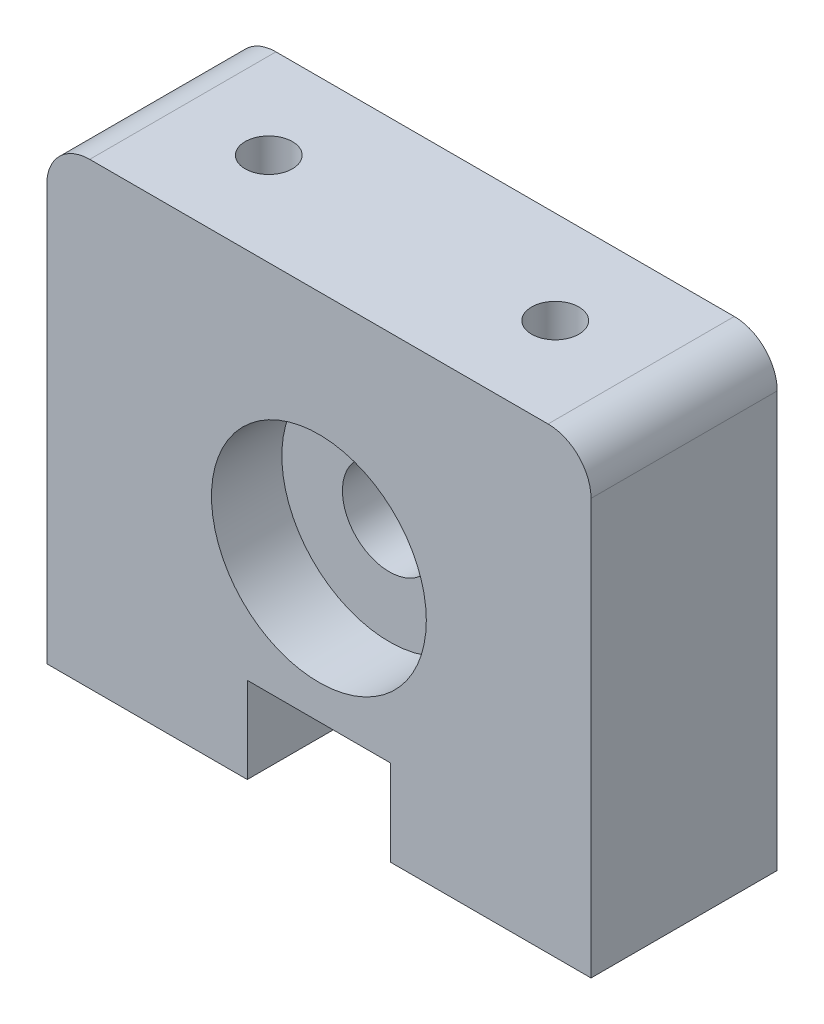
from build123d import *

# Parameters (mm, degrees)
SKETCH1_R                 = 7.5
BOSS_EXTRUDE1_DEPTH       = 13
SKETCH3_R                 = 8.7376
SKETCH3_R_2               = 3.27025
BOSS_EXTRUDE2_DEPTH       = 1.5875
BOSS_EXTRUDE2_DEPTH_BACK  = 1.5875
M4X0_7_TAPPED_HOLE1_D     = 3.3
M4X0_7_TAPPED_HOLE1_DEPTH = 10.1092
M4X0_7_TAPPED_HOLE1_TIP   = 0.991420021
M4X0_7_TAPPED_HOLE2_D     = 3.3
M4X0_7_TAPPED_HOLE2_DEPTH = 10
M4X0_7_TAPPED_HOLE2_TIP   = 0.991420021
SKETCH11_W                = 10
SKETCH11_H                = 6
CUT_EXTRUDE1_DEPTH        = 15


with BuildPart() as part:
    # Sketch1 → Boss-Extrude1 (new body)
    with BuildSketch(Plane.XY):
        with BuildLine():
            Line((-16, 32), (16, 32))
            ThreePointArc((16, 32), (18.121320344, 31.121320344), (19, 29))
            Line((19, 29), (19, 0))
            Line((19, 0), (0, 0))
            Line((0, 0), (-19, 0))
            Line((-19, 0), (-19, 29))
            ThreePointArc((-19, 29), (-18.121320344, 31.121320344), (-16, 32))
        make_face()
        with Locations((0, 15.874)):
            Circle(SKETCH1_R, mode=Mode.SUBTRACT)
    extrude(amount=BOSS_EXTRUDE1_DEPTH)

    # Sketch3 → Boss-Extrude2 (add, two sides)
    with BuildSketch(Plane.XY.offset(6.5)) as boss_extrude2_sk:
        with Locations((0, 15.874)):
            Circle(SKETCH3_R)
        with Locations((0, 15.874)):
            Circle(SKETCH3_R_2, mode=Mode.SUBTRACT)
    extrude(amount=BOSS_EXTRUDE2_DEPTH)
    extrude(boss_extrude2_sk.sketch, amount=-BOSS_EXTRUDE2_DEPTH_BACK)

    # M4x0.7 Tapped Hole1
    with Locations(Plane(origin=(0, 0, 0), x_dir=(-1, 0, 0), z_dir=(0, -1, 0))):
        with Locations((10, -6.5), (-10, -6.5)):
            Hole(M4X0_7_TAPPED_HOLE1_D / 2, depth=M4X0_7_TAPPED_HOLE1_DEPTH)
            with Locations((0, 0, -(M4X0_7_TAPPED_HOLE1_DEPTH + M4X0_7_TAPPED_HOLE1_TIP / 2))):  # 118° drill point
                Cone(0, M4X0_7_TAPPED_HOLE1_D / 2, M4X0_7_TAPPED_HOLE1_TIP, mode=Mode.SUBTRACT)

    # M4x0.7 Tapped Hole2
    with Locations(Plane(origin=(0, 32, 0), x_dir=(1, 0, 0), z_dir=(0, 1, 0))):
        with Locations((-10, -6.5), (10, -6.5)):
            Hole(M4X0_7_TAPPED_HOLE2_D / 2, depth=M4X0_7_TAPPED_HOLE2_DEPTH)
            with Locations((0, 0, -(M4X0_7_TAPPED_HOLE2_DEPTH + M4X0_7_TAPPED_HOLE2_TIP / 2))):  # 118° drill point
                Cone(0, M4X0_7_TAPPED_HOLE2_D / 2, M4X0_7_TAPPED_HOLE2_TIP, mode=Mode.SUBTRACT)

    # Sketch11 → Cut-Extrude1 (cut)
    with BuildSketch(Plane.XY.offset(13)):
        with Locations((0, 3)):
            Rectangle(SKETCH11_W, SKETCH11_H)
    extrude(amount=-CUT_EXTRUDE1_DEPTH, mode=Mode.SUBTRACT)


solid = part.part
